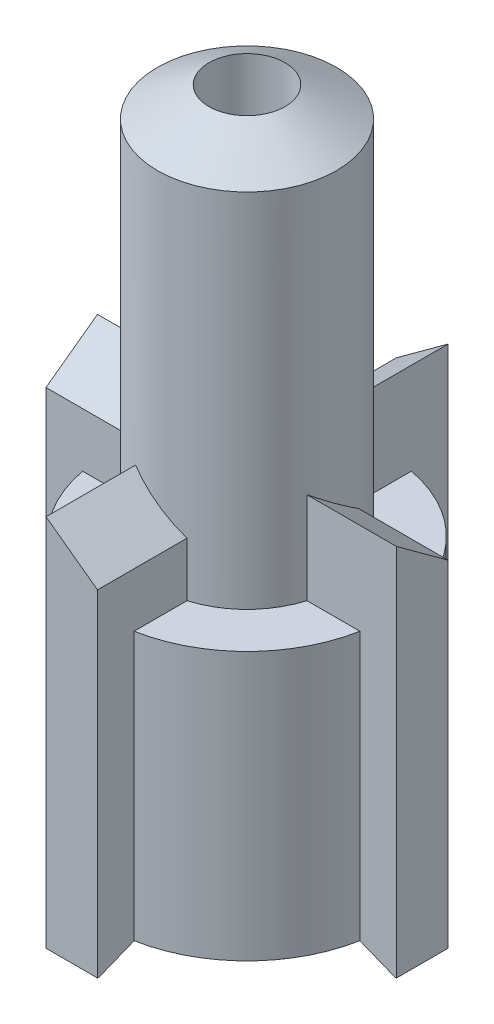
from build123d import *

# Parameters (mm, degrees)
BOSS_EXTRUDE1_START     = -6.3
BOSS_EXTRUDE1_DEPTH     = 8.35
CUT_EXTRUDE1_REACH      = 18.833
CUT_EXTRUDE1_END_RADIUS = 1.85
CIRPATTERN3_COUNT       = 4
SKETCH10_W              = 0.084438725
SKETCH10_H              = 2.05


with BuildPart() as part:
    # Sketch1 → Revolve1 (revolve)
    with BuildSketch(Plane.XY):
        Polygon((-3.15, 0), (-1.85, 0.75055535), (-1.85, 5.347868077), (-0.85, 5.347868077), (-0.85, 14.95), (-2, 14.28604719), (-2, 6.21), (-3.15, 6.21), align=None)
    revolve(axis=Axis((0, 0, 0), (0, 1, 0)))

    # Sketch3 → Boss-Extrude1 (add)
    with BuildSketch(Plane(origin=(0, 6.21, 0), x_dir=(1, 0, 0), z_dir=(0, 1, 0)).offset(BOSS_EXTRUDE1_START)):
        with BuildLine():
            Line((-0.575, -3.915561275), (0.575, -3.915561275))
            Line((0.575, -3.915561275), (0.575, -1.915561275))
            ThreePointArc((0.575, -1.915561275), (0, -2), (-0.575, -1.915561275))
            Line((-0.575, -1.915561275), (-0.575, -3.915561275))
        make_face()
    boss_extrude1 = extrude(amount=BOSS_EXTRUDE1_DEPTH)

    # Cut-Extrude1: up to this cylinder (the profile starts outside it)
    cut_extrude1_end = Plane(origin=(0, 7.980101, 0), z_dir=(0, -1, 0)) * Cylinder(CUT_EXTRUDE1_END_RADIUS, 42.366, mode=Mode.PRIVATE)
    # Sketch4 → Cut-Extrude1 (cut, up to the surface)
    with BuildSketch(Plane.XY.offset(3.915561275), mode=Mode.PRIVATE) as cut_extrude1_sk1:
        Polygon((0.575, 7.420304493), (-0.575, 8.26), (0.575, 8.26), align=None)
    cut_extrude1_tool1 = extrude(cut_extrude1_sk1.sketch, amount=-CUT_EXTRUDE1_REACH, mode=Mode.PRIVATE) - cut_extrude1_end
    cut_extrude1 = cut_extrude1_tool1.solids().sort_by_distance((0.191667, 7.980101, 3.915561))[0]
    add(cut_extrude1, mode=Mode.SUBTRACT)

    # CirPattern3: Boss-Extrude1, Cut-Extrude1 ×4 about axis
    cirpattern3_axis = Axis((0, 14.28604719, 0), (0, -1, 0))
    add([boss_extrude1.rotate(cirpattern3_axis, i * 360 / CIRPATTERN3_COUNT) for i in range(1, CIRPATTERN3_COUNT)])
    add([cut_extrude1.rotate(cirpattern3_axis, i * 360 / CIRPATTERN3_COUNT) for i in range(1, CIRPATTERN3_COUNT)], mode=Mode.SUBTRACT)

    # Sketch9 → Cut-Revolve2 (revolve, cut)
    with BuildSketch(Plane.XY):
        Polygon((-3.915561275, -0.09), (-1.85, 0.75055535), (-1.85, -0.09), align=None)
    revolve(axis=Axis((0, 0, 0), (0, -1, 0)), mode=Mode.SUBTRACT)

    # Sketch10 → Revolve2 (revolve)
    with BuildSketch(Plane.XY):
        with Locations((-1.957780637, 7.235)):
            Rectangle(SKETCH10_W, SKETCH10_H)
    revolve(axis=Axis((0, 0, 0), (0, -1, 0)))


solid = part.part
